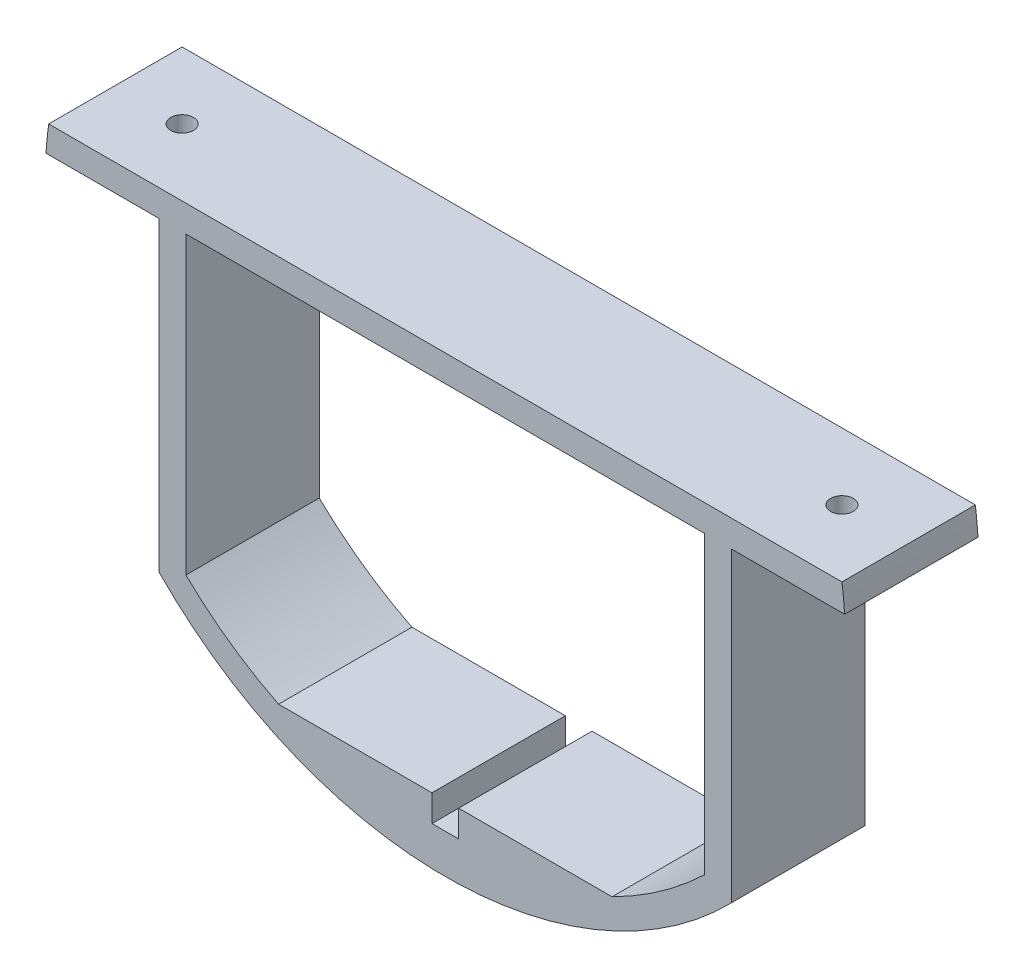
from build123d import *

# Parameters (mm, degrees)
SKETCH2_R           = 76.2
BOSS_EXTRUDE1_DEPTH = 25.4
CUT_EXTRUDE1_DEPTH  = 76.2
CUT_EXTRUDE2_DEPTH  = 76.2
SKETCH8_W           = 5.08
SKETCH8_H           = 5.08
CUT_EXTRUDE4_DEPTH  = 50.8
CUT_EXTRUDE5_DEPTH  = 26.4
SKETCH10_R          = 2.159
CUT_EXTRUDE6_DEPTH  = 25.4


with BuildPart() as part:
    # Sketch2 → Boss-Extrude1 (new body)
    with BuildSketch(Plane.XY):
        Circle(SKETCH2_R)
    extrude(amount=BOSS_EXTRUDE1_DEPTH)

    # Sketch4 → Cut-Extrude1 (cut)
    with BuildSketch(Plane.XY.offset(25.4)):
        with BuildLine():
            Line((-75.519629236, 10.16), (75.519629236, 10.16))
            ThreePointArc((75.519629236, 10.16), (0, 76.2), (-75.519629236, 10.16))
        make_face()
    extrude(amount=-CUT_EXTRUDE1_DEPTH, mode=Mode.SUBTRACT)

    # Sketch5 → Cut-Extrude2 (cut)
    with BuildSketch(Plane.XY.offset(25.4)):
        with BuildLine():
            Line((49.396930897, 5.08), (-49.396930897, 5.08))
            Line((-49.396930897, 5.08), (-49.396930897, -51.166371944))
            ThreePointArc((-49.396930897, -51.166371944), (-41.049983197, -58.077132157), (-31.75, -63.639546667))
            Line((-31.75, -63.639546667), (31.75, -63.639546667))
            ThreePointArc((31.75, -63.639546667), (41.049983197, -58.077132157), (49.396930897, -51.166371944))
            Line((49.396930897, -51.166371944), (49.396930897, 5.08))
        make_face()
    extrude(amount=-CUT_EXTRUDE2_DEPTH, mode=Mode.SUBTRACT)

    # Sketch8 → Cut-Extrude4 (cut)
    with BuildSketch(Plane.XY.offset(25.4)):
        with Locations((0, -66.179546667)):
            Rectangle(SKETCH8_W, SKETCH8_H)
    extrude(amount=-CUT_EXTRUDE4_DEPTH, mode=Mode.SUBTRACT)

    # Sketch9 → Cut-Extrude5 (cut, through all)
    with BuildSketch(Plane.XY.offset(25.4)):
        with BuildLine():
            Line((54.476930897, 5.08), (76.030478099, 5.08))
            ThreePointArc((76.030478099, 5.08), (71.480790805, -26.399555791), (54.476930897, -53.279489487))
            Line((54.476930897, -53.279489487), (54.476930897, 5.08))
        make_face()
        with BuildLine():
            Line((-54.476930897, 5.08), (-54.476930897, -53.279489487))
            ThreePointArc((-54.476930897, -53.279489487), (-71.480790805, -26.399555791), (-76.030478099, 5.08))
            Line((-76.030478099, 5.08), (-54.476930897, 5.08))
        make_face()
    extrude(amount=-CUT_EXTRUDE5_DEPTH, mode=Mode.SUBTRACT)

    # Sketch10 → Cut-Extrude6 (cut)
    with BuildSketch(Plane(origin=(0, 10.16, 0), x_dir=(1, 0, 0), z_dir=(0, 1, 0))):
        with Locations((62.819629236, -12.7)):
            Circle(SKETCH10_R)
        with Locations((-62.819629236, -12.7)):
            Circle(SKETCH10_R)
    extrude(amount=-CUT_EXTRUDE6_DEPTH, mode=Mode.SUBTRACT)


solid = part.part
